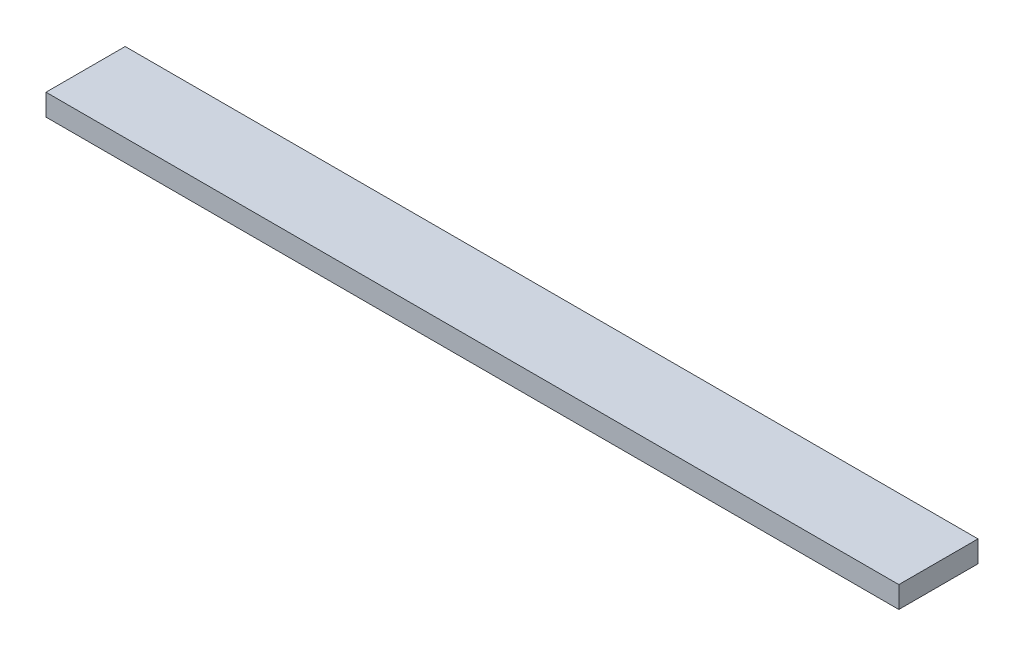
from build123d import *

# Parameters (mm, degrees)
SKETCH1_W           = 752.475
SKETCH1_H           = 69.85
BOSS_EXTRUDE1_DEPTH = 19.05


with BuildPart() as part:
    # Sketch1 → Boss-Extrude1 (new body)
    with BuildSketch(Plane(origin=(0, 0, 0), x_dir=(1, 0, 0), z_dir=(0, 1, 0))):
        with Locations((376.2375, 34.925)):
            Rectangle(SKETCH1_W, SKETCH1_H)
    extrude(amount=BOSS_EXTRUDE1_DEPTH)


solid = part.part
